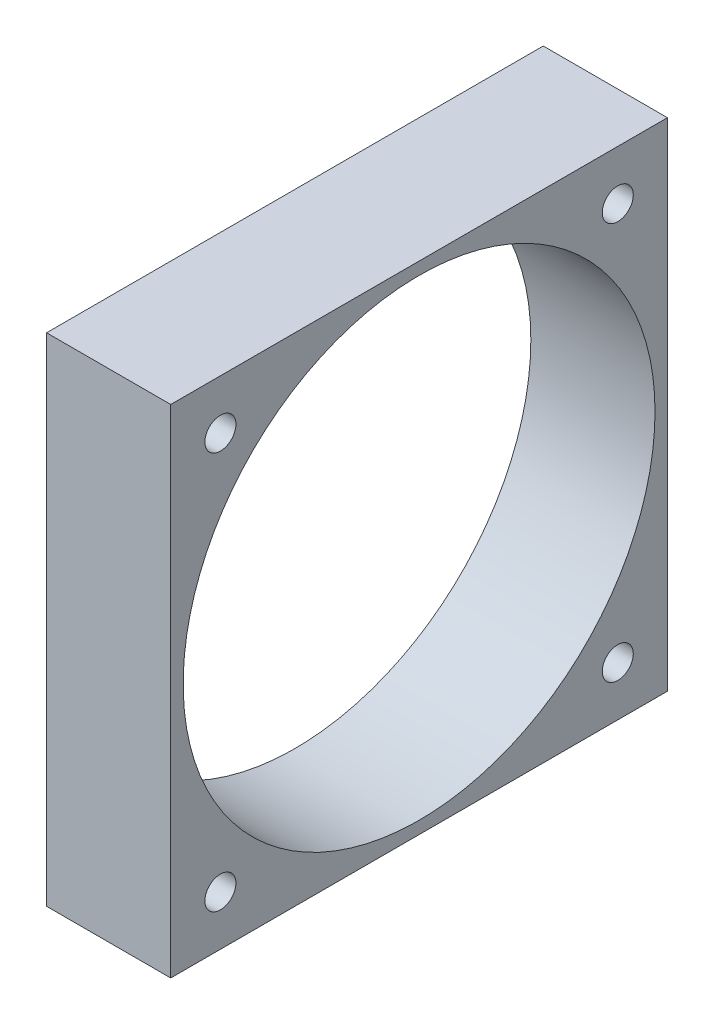
from build123d import *

# Parameters (mm, degrees)
SKETCH1_W           = 40
SKETCH1_H           = 40
SKETCH1_R           = 19
SKETCH1_R_2         = 1.25
BOSS_EXTRUDE1_DEPTH = 10


with BuildPart() as part:
    # Sketch1 → Boss-Extrude1 (new body)
    with BuildSketch(Plane(origin=(0, 0, 0), x_dir=(0, 0, -1), z_dir=(1, 0, 0))):
        Rectangle(SKETCH1_W, SKETCH1_H)
        Circle(SKETCH1_R, mode=Mode.SUBTRACT)
        with Locations((-16, 16)):
            Circle(SKETCH1_R_2, mode=Mode.SUBTRACT)
        with Locations((16, 16)):
            Circle(SKETCH1_R_2, mode=Mode.SUBTRACT)
        with Locations((16, -16)):
            Circle(SKETCH1_R_2, mode=Mode.SUBTRACT)
        with Locations((-16, -16)):
            Circle(SKETCH1_R_2, mode=Mode.SUBTRACT)
    extrude(amount=BOSS_EXTRUDE1_DEPTH)


solid = part.part
